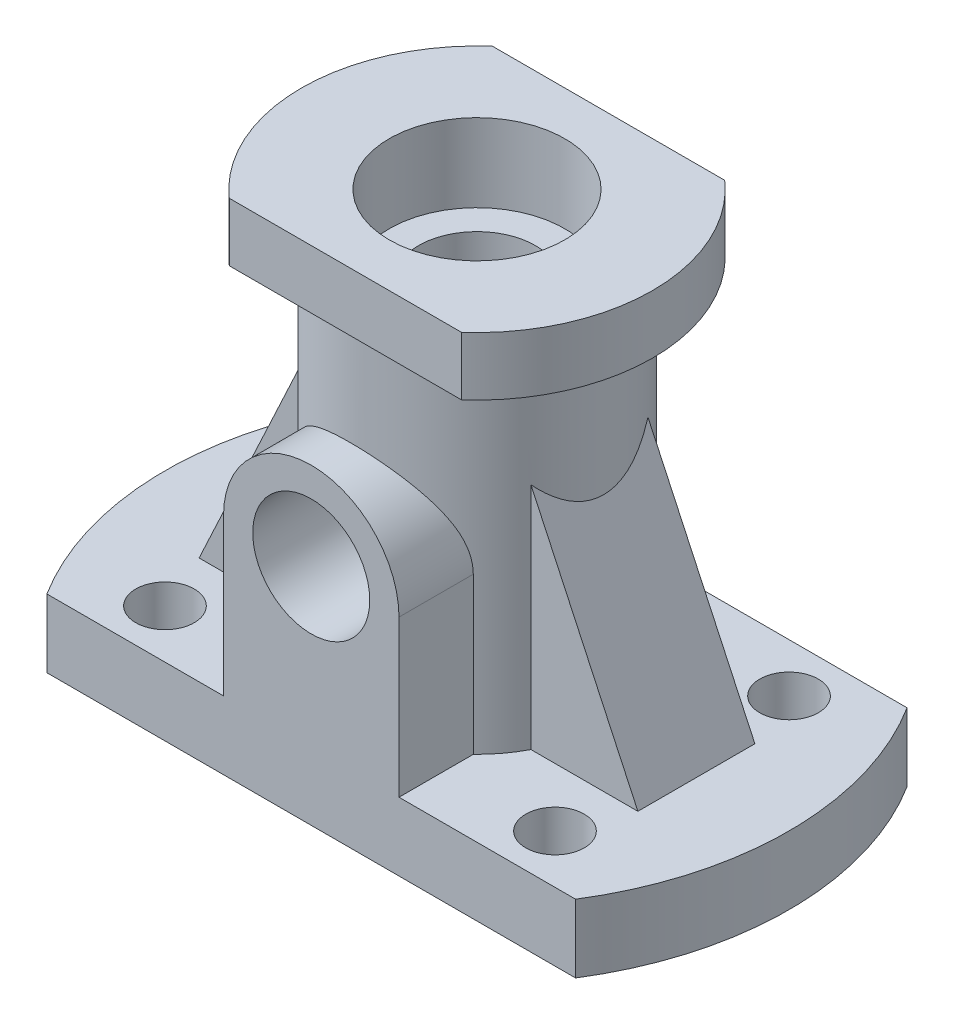
from build123d import *

# Parameters (mm, degrees)
EXTRUDE_1_DEPTH          = 7
SKETCH_2_R               = 3
CUT_EXTRUDE_1_DEPTH      = 8
MIRROR_2_COPY_1_SKETCH_R = 3
MIRROR_2_COPY_1_DEPTH    = 8
SKETCH_3_R               = 13
EXTRUDE_2_DEPTH          = 35
EXTRUDE_3_DEPTH          = 6
SKETCH_5_R               = 9
CUT_EXTRUDE_2_DEPTH      = 8
SKETCH_6_R               = 6
CUT_EXTRUDE_3_DEPTH      = 41
EXTRUDE_4_REACH          = 36
CUT_EXTRUDE_4_REACH      = 36
SKETCH_8_R               = 6
EXTRUDE_5_DEPTH          = 6


with BuildPart() as part:
    # 草图1 → 凸台-拉伸1 (new body)
    with BuildSketch(Plane(origin=(0, 0, 0), x_dir=(1, 0, 0), z_dir=(0, 1, 0))):
        with BuildLine():
            Line((-27.110883423, 17), (27.110883423, 17))
            ThreePointArc((27.110883423, 17), (32, 0), (27.110883423, -17))
            Line((27.110883423, -17), (-27.110883423, -17))
            ThreePointArc((-27.110883423, -17), (-32, 0), (-27.110883423, 17))
        make_face()
    extrude(amount=EXTRUDE_1_DEPTH)

    # 草图2 → 切除-拉伸1 (cut, through all)
    with BuildSketch(Plane(origin=(0, 7, 0), x_dir=(1, 0, 0), z_dir=(0, 1, 0))):
        with Locations((-20, -12)):
            Circle(SKETCH_2_R)
    cut_extrude_1 = extrude(amount=-CUT_EXTRUDE_1_DEPTH, mode=Mode.SUBTRACT)

    # 镜向1: 切除-拉伸1 across plane
    add(cut_extrude_1.mirror(Plane(origin=(0, 0, 0), x_dir=(0, 0, 1), z_dir=(1, 0, 0))), mode=Mode.SUBTRACT)

    # 镜向2: 切除-拉伸1 across plane
    add(cut_extrude_1.mirror(Plane.XY), mode=Mode.SUBTRACT)

    # 镜向2 copy 1 sketch → 镜向2 copy 1 (cut, through all)
    with BuildSketch(Plane(origin=(0, 7, 0), x_dir=(-1, 0, 0), z_dir=(0, 1, 0))):
        with Locations((-20, -12)):
            Circle(MIRROR_2_COPY_1_SKETCH_R)
    extrude(amount=-MIRROR_2_COPY_1_DEPTH, mode=Mode.SUBTRACT)

    # 草图3 → 凸台-拉伸2 (add)
    with BuildSketch(Plane(origin=(0, 7, 0), x_dir=(1, 0, 0), z_dir=(0, 1, 0))):
        Circle(SKETCH_3_R)
    extrude(amount=EXTRUDE_2_DEPTH)

    # 草图4 → 凸台-拉伸3 (add)
    with BuildSketch(Plane(origin=(0, 42, 0), x_dir=(1, 0, 0), z_dir=(0, 1, 0))):
        with BuildLine():
            Line((-11.9058809, 13.5), (11.9058809, 13.5))
            ThreePointArc((11.9058809, 13.5), (18, 0), (11.9058809, -13.5))
            Line((11.9058809, -13.5), (-11.9058809, -13.5))
            ThreePointArc((-11.9058809, -13.5), (-18, 0), (-11.9058809, 13.5))
        make_face()
    extrude(amount=EXTRUDE_3_DEPTH)

    # 草图5 → 切除-拉伸2 (cut)
    with BuildSketch(Plane(origin=(0, 48, 0), x_dir=(1, 0, 0), z_dir=(0, 1, 0))):
        Circle(SKETCH_5_R)
    extrude(amount=-CUT_EXTRUDE_2_DEPTH, mode=Mode.SUBTRACT)

    # 草图6 → 切除-拉伸3 (cut, through all)
    with BuildSketch(Plane(origin=(0, 40, 0), x_dir=(1, 0, 0), z_dir=(0, 1, 0))):
        Circle(SKETCH_6_R)
    extrude(amount=-CUT_EXTRUDE_3_DEPTH, mode=Mode.SUBTRACT)

    # 草图7 → 凸台-拉伸4 (add, up to next)
    with BuildSketch(Plane.XY.offset(17), mode=Mode.PRIVATE) as extrude_4_sk1:
        with BuildLine():
            Line((-9, 23), (-9, 0))
            Line((-9, 0), (9, 0))
            Line((9, 0), (9, 23))
            ThreePointArc((9, 23), (0, 32), (-9, 23))
        make_face()
    extrude_4_tool1 = extrude(extrude_4_sk1.sketch, amount=-EXTRUDE_4_REACH, mode=Mode.PRIVATE) - part.part
    add(extrude_4_tool1.solids().sort_by_distance((0, 15.10139, 17))[0])

    # 草图8 → 切除-拉伸4 (cut, up to next)
    with BuildSketch(Plane.XY.offset(17), mode=Mode.PRIVATE) as cut_extrude_4_sk1:
        with Locations((0, 23)):
            Circle(SKETCH_8_R)
    cut_extrude_4_tool1 = extrude(cut_extrude_4_sk1.sketch, amount=-CUT_EXTRUDE_4_REACH, mode=Mode.PRIVATE) & part.part
    add(cut_extrude_4_tool1.solids().sort_by_distance((0, 23, 17))[0], mode=Mode.SUBTRACT)

    # 草图9 → 凸台-拉伸5 (add, symmetric)
    with BuildSketch(Plane.XY):
        Polygon((-22.5, 7), (-11.086673611, 7), (-11.086673611, 31.475957428), align=None)
    extrude_5 = extrude(amount=EXTRUDE_5_DEPTH, both=True)

    # 镜向3: 凸台-拉伸5 across plane
    add(extrude_5.mirror(Plane(origin=(0, 0, 0), x_dir=(0, 0, 1), z_dir=(1, 0, 0))))


solid = part.part
